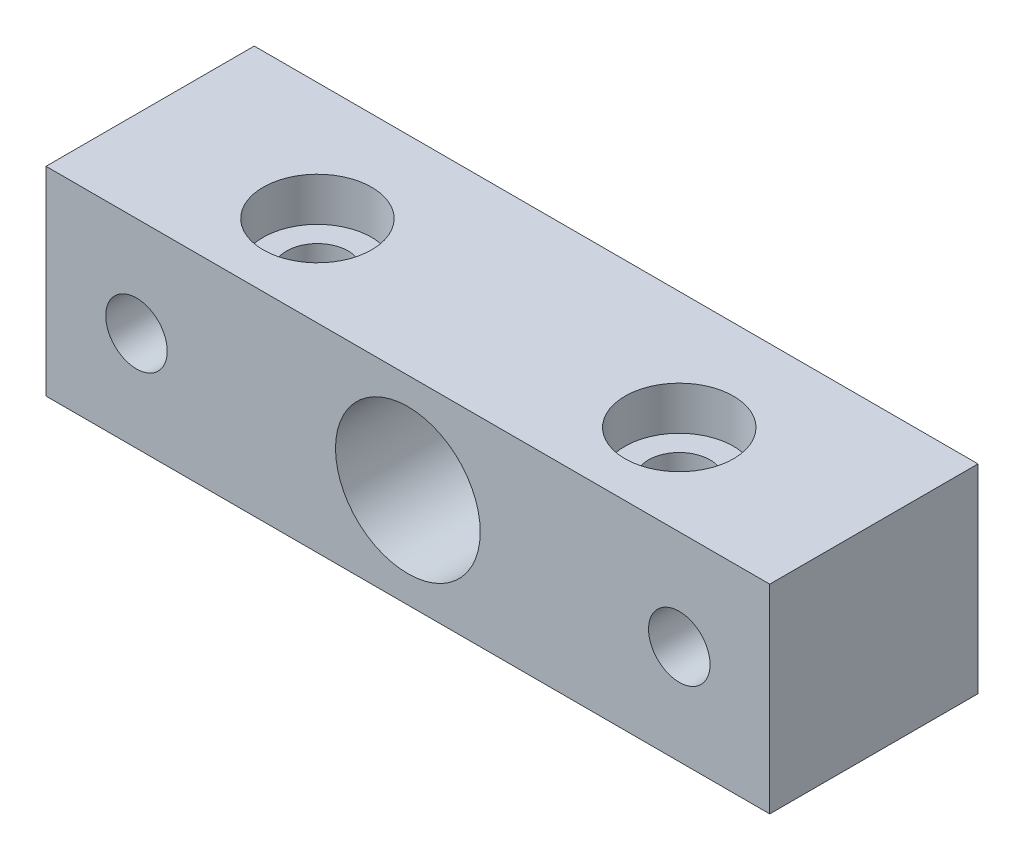
from build123d import *

# Parameters (mm, degrees)
ESQUISSE1_W                                        = 40
ESQUISSE1_H                                        = 11
ESQUISSE1_R                                        = 4
BOSS_EXTRU_1_DEPTH                                 = 10.51
ESQUISSE16_W                                       = 40
ESQUISSE16_H                                       = 11
BOSS_EXTRU_2_DEPTH                                 = 7
D_GAGEMENT_M32_D                                   = 2.5
CHAMBRAGE_POUR_VIS_T_TE_RONDE_BOMB_E_M_D           = 3.4
CHAMBRAGE_POUR_VIS_T_TE_RONDE_BOMB_E_M_CBORE_D     = 6
CHAMBRAGE_POUR_VIS_T_TE_RONDE_BOMB_E_M_CBORE_DEPTH = 2.4
FRAISAGE_POUR_VIS_T_TE_FRAIS_E_M31_D               = 3.4
FRAISAGE_POUR_VIS_T_TE_FRAIS_E_M31_DEPTH           = 8
FRAISAGE_POUR_VIS_T_TE_FRAIS_E_M31_CSINK_D         = 6.3
FRAISAGE_POUR_VIS_T_TE_FRAIS_E_M31_CSINK_ANGLE     = 90
FRAISAGE_POUR_VIS_T_TE_FRAIS_E_M31_TIP             = 1.021463052
ESQUISSE33_W                                       = 100.854971174
ESQUISSE33_H                                       = 90.146734576
ENL_V_MAT_EXTRU_4_DEPTH                            = 3
ESQUISSE34_R                                       = 4
ENL_V_MAT_EXTRU_5_DEPTH                            = 10
ESQUISSE35_W                                       = 78.795727906
ESQUISSE35_H                                       = 40.956962542
ENL_V_MAT_EXTRU_6_DEPTH                            = 3


with BuildPart() as part:
    # Esquisse1 → Boss.-Extru.1 (new body)
    with BuildSketch(Plane.XY):
        Rectangle(ESQUISSE1_W, ESQUISSE1_H)
        Circle(ESQUISSE1_R, mode=Mode.SUBTRACT)
    extrude(amount=BOSS_EXTRU_1_DEPTH)

    # Esquisse16 → Boss.-Extru.2 (add)
    with BuildSketch(Plane.XY.offset(10.51)):
        Rectangle(ESQUISSE16_W, ESQUISSE16_H)
    extrude(amount=BOSS_EXTRU_2_DEPTH)

    # Dégagement M32 (through all)
    with Locations(Plane.XY.offset(17.51)):
        with Locations((0, 0)):
            Hole(D_GAGEMENT_M32_D / 2)

    # Chambrage pour vis _ t_te ronde bomb_e M (through all)
    with Locations(Plane(origin=(0, 5.5, 0), x_dir=(1, 0, 0), z_dir=(0, 1, 0))):
        with Locations((10, -9.51), (-10, -9.51)):
            CounterBoreHole(CHAMBRAGE_POUR_VIS_T_TE_RONDE_BOMB_E_M_D / 2, CHAMBRAGE_POUR_VIS_T_TE_RONDE_BOMB_E_M_CBORE_D / 2, CHAMBRAGE_POUR_VIS_T_TE_RONDE_BOMB_E_M_CBORE_DEPTH)

    # Fraisage pour vis à tête fraisée M31
    with Locations(Plane.XY.offset(17.51)):
        with Locations((-15, 0), (15, 0)):
            CounterSinkHole(FRAISAGE_POUR_VIS_T_TE_FRAIS_E_M31_D / 2, FRAISAGE_POUR_VIS_T_TE_FRAIS_E_M31_CSINK_D / 2, depth=FRAISAGE_POUR_VIS_T_TE_FRAIS_E_M31_DEPTH, counter_sink_angle=FRAISAGE_POUR_VIS_T_TE_FRAIS_E_M31_CSINK_ANGLE)
            with Locations((0, 0, -(FRAISAGE_POUR_VIS_T_TE_FRAIS_E_M31_DEPTH + FRAISAGE_POUR_VIS_T_TE_FRAIS_E_M31_TIP / 2))):  # 118° drill point
                Cone(0, FRAISAGE_POUR_VIS_T_TE_FRAIS_E_M31_D / 2, FRAISAGE_POUR_VIS_T_TE_FRAIS_E_M31_TIP, mode=Mode.SUBTRACT)

    # Esquisse33 → Enlèv. mat.-Extru.4 (cut)
    with BuildSketch(Plane.XY.offset(17.51)):
        Rectangle(ESQUISSE33_W, ESQUISSE33_H)
    extrude(amount=-ENL_V_MAT_EXTRU_4_DEPTH, mode=Mode.SUBTRACT)

    # Esquisse34 → Enlèv. mat.-Extru.5 (cut)
    with BuildSketch(Plane.XY.offset(14.51)):
        Circle(ESQUISSE34_R)
    extrude(amount=-ENL_V_MAT_EXTRU_5_DEPTH, mode=Mode.SUBTRACT)

    # Esquisse35 → Enlèv. mat.-Extru.6 (cut)
    with BuildSketch(Plane(origin=(0, 0, 0), x_dir=(-1, 0, 0), z_dir=(0, 0, -1))):
        Rectangle(ESQUISSE35_W, ESQUISSE35_H)
    extrude(amount=-ENL_V_MAT_EXTRU_6_DEPTH, mode=Mode.SUBTRACT)


solid = part.part
